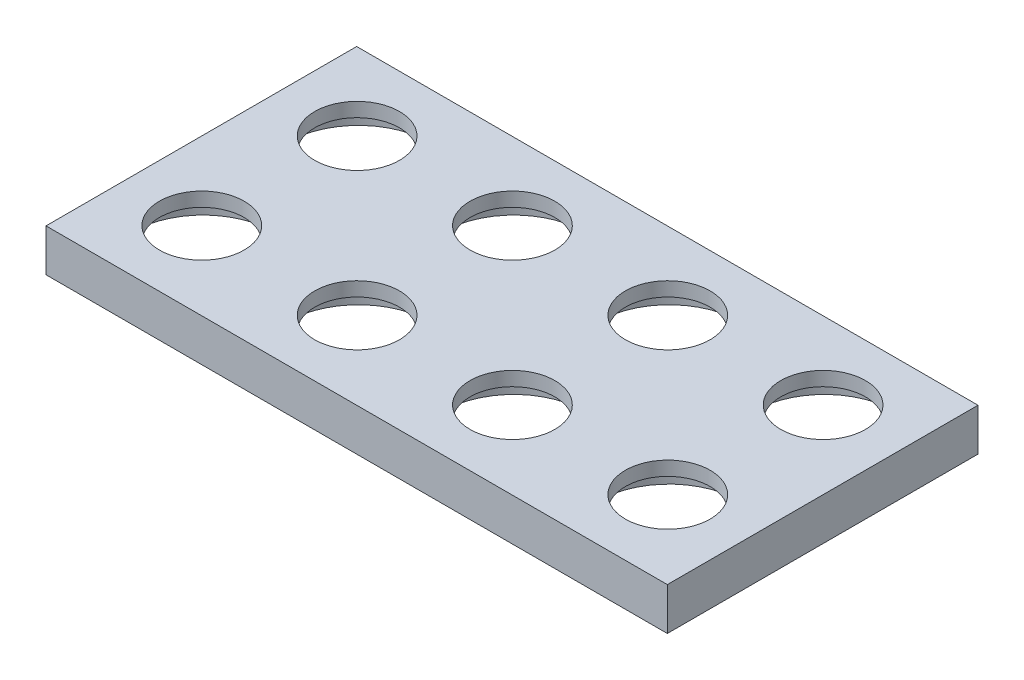
from build123d import *

# Parameters (mm, degrees)
SKETCH2_W                 = 22
SKETCH2_H                 = 22
BOSS_EXTRUDE1_DEPTH       = 6
SKETCH3_R                 = 6
CUT_EXTRUDE1_DEPTH        = 2
SKETCH4_R                 = 10.175
CUT_EXTRUDE2_DEPTH        = 4
LPATTERN1_COUNT           = 4
LPATTERN1_PITCH           = 22
LPATTERN2_COUNT           = 2
LPATTERN2_PITCH           = 22
LPATTERN2_COPY_1_SKETCH_W = 22
LPATTERN2_COPY_1_SKETCH_H = 22
LPATTERN2_COPY_1_DEPTH    = 6
LPATTERN2_COPY_2_SKETCH_W = 22
LPATTERN2_COPY_2_SKETCH_H = 22
LPATTERN2_COPY_2_DEPTH    = 6
LPATTERN2_COPY_3_SKETCH_W = 22
LPATTERN2_COPY_3_SKETCH_H = 22
LPATTERN2_COPY_3_DEPTH    = 6
LPATTERN2_COPY_4_SKETCH_R = 6
LPATTERN2_COPY_4_DEPTH    = 2
LPATTERN2_COPY_5_SKETCH_R = 6
LPATTERN2_COPY_5_DEPTH    = 2
LPATTERN2_COPY_6_SKETCH_R = 6
LPATTERN2_COPY_6_DEPTH    = 2
LPATTERN2_COPY_7_SKETCH_R = 10.175
LPATTERN2_COPY_7_DEPTH    = 4
LPATTERN2_COPY_8_SKETCH_R = 10.175
LPATTERN2_COPY_8_DEPTH    = 4
LPATTERN2_COPY_9_SKETCH_R = 10.175
LPATTERN2_COPY_9_DEPTH    = 4


with BuildPart() as part:
    # Sketch2 → Boss-Extrude1 (new body)
    with BuildSketch(Plane(origin=(0, 0, 0), x_dir=(1, 0, 0), z_dir=(0, 1, 0))):
        with Locations((11, 11)):
            Rectangle(SKETCH2_W, SKETCH2_H)
    boss_extrude1 = extrude(amount=-BOSS_EXTRUDE1_DEPTH)

    # Sketch3 → Cut-Extrude1 (cut)
    with BuildSketch(Plane(origin=(0, 0, 0), x_dir=(1, 0, 0), z_dir=(0, 1, 0))):
        with Locations(Location((11, 11.062224767, 0), (0, 0, 270))):
            Circle(SKETCH3_R)
    cut_extrude1 = extrude(amount=-CUT_EXTRUDE1_DEPTH, mode=Mode.SUBTRACT)

    # Sketch4 → Cut-Extrude2 (cut)
    with BuildSketch(Plane.XZ.offset(6)):
        with Locations(Location((11, -11.253914961, 0), (0, 0, 270))):
            Circle(SKETCH4_R)
    cut_extrude2 = extrude(amount=-CUT_EXTRUDE2_DEPTH, mode=Mode.SUBTRACT)

    # LPattern1: Boss-Extrude1, Cut-Extrude1, Cut-Extrude2 ×4
    with Locations(*[(-i * LPATTERN1_PITCH, 0, 0) for i in range(1, LPATTERN1_COUNT)]):
        add(boss_extrude1)
        add(cut_extrude1, mode=Mode.SUBTRACT)
        add(cut_extrude2, mode=Mode.SUBTRACT)

    # LPattern2: Boss-Extrude1, Cut-Extrude1, Cut-Extrude2 ×2
    with Locations(*[(0, 0, -i * LPATTERN2_PITCH) for i in range(1, LPATTERN2_COUNT)]):
        add(boss_extrude1)
        add(cut_extrude1, mode=Mode.SUBTRACT)
        add(cut_extrude2, mode=Mode.SUBTRACT)

    # LPattern2 copy 1 sketch → LPattern2 copy 1 (add)
    with BuildSketch(Plane(origin=(-22, 0, -22), x_dir=(1, 0, 0), z_dir=(0, 1, 0))):
        with Locations((11, 11)):
            Rectangle(LPATTERN2_COPY_1_SKETCH_W, LPATTERN2_COPY_1_SKETCH_H)
    extrude(amount=-LPATTERN2_COPY_1_DEPTH)

    # LPattern2 copy 2 sketch → LPattern2 copy 2 (add)
    with BuildSketch(Plane(origin=(-44, 0, -22), x_dir=(1, 0, 0), z_dir=(0, 1, 0))):
        with Locations((11, 11)):
            Rectangle(LPATTERN2_COPY_2_SKETCH_W, LPATTERN2_COPY_2_SKETCH_H)
    extrude(amount=-LPATTERN2_COPY_2_DEPTH)

    # LPattern2 copy 3 sketch → LPattern2 copy 3 (add)
    with BuildSketch(Plane(origin=(-66, 0, -22), x_dir=(1, 0, 0), z_dir=(0, 1, 0))):
        with Locations((11, 11)):
            Rectangle(LPATTERN2_COPY_3_SKETCH_W, LPATTERN2_COPY_3_SKETCH_H)
    extrude(amount=-LPATTERN2_COPY_3_DEPTH)

    # LPattern2 copy 4 sketch → LPattern2 copy 4 (cut)
    with BuildSketch(Plane(origin=(-22, 0, -22), x_dir=(1, 0, 0), z_dir=(0, 1, 0))):
        with Locations(Location((11, 11.062224767, 0), (0, 0, 270))):
            Circle(LPATTERN2_COPY_4_SKETCH_R)
    extrude(amount=-LPATTERN2_COPY_4_DEPTH, mode=Mode.SUBTRACT)

    # LPattern2 copy 5 sketch → LPattern2 copy 5 (cut)
    with BuildSketch(Plane(origin=(-44, 0, -22), x_dir=(1, 0, 0), z_dir=(0, 1, 0))):
        with Locations(Location((11, 11.062224767, 0), (0, 0, 270))):
            Circle(LPATTERN2_COPY_5_SKETCH_R)
    extrude(amount=-LPATTERN2_COPY_5_DEPTH, mode=Mode.SUBTRACT)

    # LPattern2 copy 6 sketch → LPattern2 copy 6 (cut)
    with BuildSketch(Plane(origin=(-66, 0, -22), x_dir=(1, 0, 0), z_dir=(0, 1, 0))):
        with Locations(Location((11, 11.062224767, 0), (0, 0, 270))):
            Circle(LPATTERN2_COPY_6_SKETCH_R)
    extrude(amount=-LPATTERN2_COPY_6_DEPTH, mode=Mode.SUBTRACT)

    # LPattern2 copy 7 sketch → LPattern2 copy 7 (cut)
    with BuildSketch(Plane(origin=(-22, -6, -22), x_dir=(1, 0, 0), z_dir=(0, -1, 0))):
        with Locations(Location((11, -11.253914961, 0), (0, 0, 270))):
            Circle(LPATTERN2_COPY_7_SKETCH_R)
    extrude(amount=-LPATTERN2_COPY_7_DEPTH, mode=Mode.SUBTRACT)

    # LPattern2 copy 8 sketch → LPattern2 copy 8 (cut)
    with BuildSketch(Plane(origin=(-44, -6, -22), x_dir=(1, 0, 0), z_dir=(0, -1, 0))):
        with Locations(Location((11, -11.253914961, 0), (0, 0, 270))):
            Circle(LPATTERN2_COPY_8_SKETCH_R)
    extrude(amount=-LPATTERN2_COPY_8_DEPTH, mode=Mode.SUBTRACT)

    # LPattern2 copy 9 sketch → LPattern2 copy 9 (cut)
    with BuildSketch(Plane(origin=(-66, -6, -22), x_dir=(1, 0, 0), z_dir=(0, -1, 0))):
        with Locations(Location((11, -11.253914961, 0), (0, 0, 270))):
            Circle(LPATTERN2_COPY_9_SKETCH_R)
    extrude(amount=-LPATTERN2_COPY_9_DEPTH, mode=Mode.SUBTRACT)


solid = part.part
